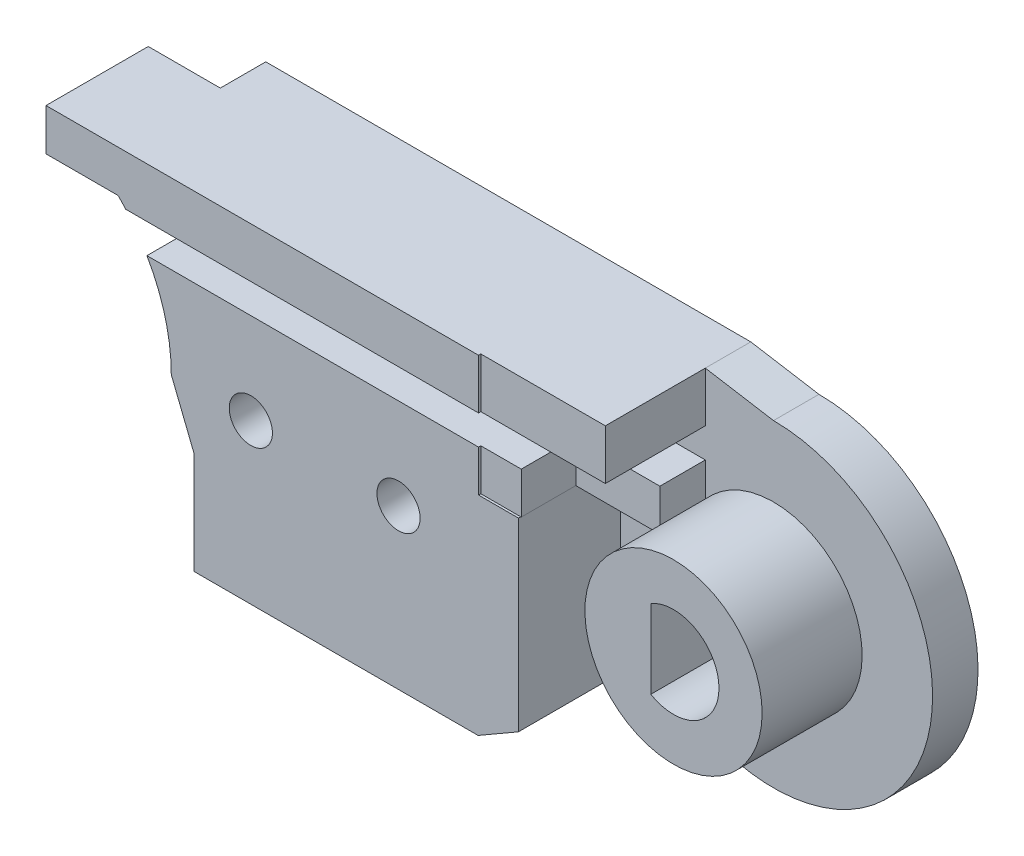
from build123d import *

# Parameters (mm, degrees)
BOSS_EXTRUDE1_DEPTH  = 2
BOSS_EXTRUDE6_DEPTH  = 4.5
CUT_EXTRUDE6_DEPTH   = 4.5
BOSS_EXTRUDE14_DEPTH = 2.3
SKETCH32_R           = 2.1
CUT_EXTRUDE7_DEPTH   = 2.3
SKETCH33_W           = 12.5
SKETCH33_H           = 1.343145751
BOSS_EXTRUDE15_DEPTH = 1.2
SKETCH35_W           = 5.479645997
SKETCH35_H           = 5.327993755
CUT_EXTRUDE8_DEPTH   = 2.4
SKETCH36_W           = 3.7
SKETCH36_H           = 1.827993755
CUT_EXTRUDE9_DEPTH   = 2.4
SKETCH37_R           = 3.9
BOSS_EXTRUDE16_DEPTH = 4.4
CUT_EXTRUDE10_DEPTH  = 7.4
SKETCH43_R           = 2.5
BOSS_EXTRUDE17_DEPTH = 1.2
SKETCH44_R           = 0.95
CUT_EXTRUDE11_DEPTH  = 11
SKETCH45_R           = 2
CUT_EXTRUDE12_DEPTH  = 4.5
SKETCH52_R           = 0.75
CUT_EXTRUDE13_DEPTH  = 10


with BuildPart() as part:
    # Sketch3 → Boss-Extrude1 (new body)
    with BuildSketch(Plane.XY):
        with BuildLine():
            Line((8, 0), (9, -2.5))
            Line((9, -2.5), (9, -7))
            Line((9, -7), (21.5, -7))
            Line((21.5, -7), (25.050252532, -4.949747468))
            ThreePointArc((25.050252532, -4.949747468), (36.467156728, -2.678784027), (30, 7))
            Line((30, 7), (27, 7.5))
            Line((27, 7.5), (5.656854249, 7.5))
            Line((5.656854249, 7.5), (5.656854249, 5.656854249))
            ThreePointArc((5.656854249, 5.656854249), (7.39103626, 3.061467459), (8, 0))
        make_face()
    extrude(amount=BOSS_EXTRUDE1_DEPTH)

    # Sketch22 → Boss-Extrude6 (add)
    with BuildSketch(Plane.XY.offset(2)):
        with BuildLine():
            Line((5.656854249, 5.656854249), (2.486790148, 5.656854249))
            Line((2.486790148, 5.656854249), (2.486790148, 7.5))
            Line((2.486790148, 7.5), (5.656854249, 7.5))
            Line((5.656854249, 7.5), (21.5, 7.5))
            Line((21.5, 7.5), (27, 7.5))
            Line((27, 7.5), (27, 2.172006245))
            Line((27, 2.172006245), (23.275126266, 2.172006245))
            Line((23.275126266, 2.172006245), (23.275126266, -5.974873734))
            Line((23.275126266, -5.974873734), (21.5, -7))
            Line((21.5, -7), (9, -7))
            Line((9, -7), (9, -2.5))
            Line((9, -2.5), (8, 0))
            ThreePointArc((8, 0), (7.39103626, 3.061467459), (5.656854249, 5.656854249))
        make_face()
    extrude(amount=BOSS_EXTRUDE6_DEPTH)

    # Sketch26 → Cut-Extrude6 (cut)
    with BuildSketch(Plane.XY.offset(2)):
        Polygon((18.098080448, 5.3), (2.530052458, 5.3), (2.530052458, 4), (18.098080448, 4), (27, 4), (27, 5.3), align=None)
    extrude(amount=CUT_EXTRUDE6_DEPTH, mode=Mode.SUBTRACT)


with BuildPart() as body_2:
    # Sketch31 → Boss-Extrude14 (new body)
    with BuildSketch(Plane.XY.offset(6.5)):
        with BuildLine():
            Line((2.432688066, 5.656854249), (0, 5.656854249))
            ThreePointArc((0, 5.656854249), (-5.656854249, 0), (0, -5.656854249))
            Line((0, -5.656854249), (9, -5.656854249))
            Line((9, -5.656854249), (9, -7))
            Line((9, -7), (21.5, -7))
            Line((21.5, -7), (23.275126266, -5.974873734))
            Line((23.275126266, -5.974873734), (23.275126266, 2.172006245))
            Line((23.275126266, 2.172006245), (27, 2.172006245))
            Line((27, 2.172006245), (27, 7.5))
            Line((27, 7.5), (2.486790148, 7.5))
            Line((2.486790148, 7.5), (2.432688066, 5.656854249))
        make_face()
    extrude(amount=BOSS_EXTRUDE14_DEPTH)

    # Sketch32 → Cut-Extrude7 (cut)
    with BuildSketch(Plane.XY.offset(8.8)):
        Circle(SKETCH32_R)
    extrude(amount=-CUT_EXTRUDE7_DEPTH, mode=Mode.SUBTRACT)

    # Sketch33 → Boss-Extrude15 (add)
    with BuildSketch(Plane.XY.offset(8.8)):
        with Locations((15.25, -6.328427125)):
            Rectangle(SKETCH33_W, SKETCH33_H)
        Polygon((2.486790148, 7.5), (21.5, 7.5), (21.5, 5.656854249), (2.432688066, 5.656854249), align=None)
    extrude(amount=BOSS_EXTRUDE15_DEPTH)


with BuildPart() as cut_extrude8_tool:
    # Sketch35 → Cut-Extrude8 (new body)
    with BuildSketch(Plane.XY.offset(8.8)):
        with Locations((24.260177002, 4.836003123)):
            Rectangle(SKETCH35_W, SKETCH35_H)
    extrude(amount=-CUT_EXTRUDE8_DEPTH)


with BuildPart() as part_1:
    add(part.part)

    # Cut-Extrude8: cut by cut_extrude8_tool
    add(cut_extrude8_tool.part, mode=Mode.SUBTRACT)

    # Sketch36 → Cut-Extrude9 (cut)
    with BuildSketch(Plane.XY.offset(6.4)):
        with Locations((25.15, 3.086003123)):
            Rectangle(SKETCH36_W, SKETCH36_H)
    extrude(amount=-CUT_EXTRUDE9_DEPTH, mode=Mode.SUBTRACT)

    # Sketch37 → Boss-Extrude16 (add)
    with BuildSketch(Plane.XY.offset(2)):
        with Locations((30, 0)):
            Circle(SKETCH37_R)
    extrude(amount=BOSS_EXTRUDE16_DEPTH)

    # Sketch39 → Cut-Extrude10 (cut, through all)
    with BuildSketch(Plane.XY.offset(6.4)):
        with BuildLine():
            Line((29, 1.732050808), (29, -1.732050808))
            ThreePointArc((29, -1.732050808), (32, 0), (29, 1.732050808))
        make_face()
    extrude(amount=-CUT_EXTRUDE10_DEPTH, mode=Mode.SUBTRACT)


with BuildPart() as body_2_1:
    add(body_2.part)

    # Cut-Extrude8: cut by cut_extrude8_tool
    add(cut_extrude8_tool.part, mode=Mode.SUBTRACT)

    # Sketch43 → Boss-Extrude17 (add)
    with BuildSketch(Plane.XY.offset(8.8)):
        with Locations((11.5, 0)):
            Circle(SKETCH43_R)
        with Locations((18, 0)):
            Circle(SKETCH43_R)
    extrude(amount=BOSS_EXTRUDE17_DEPTH)


with BuildPart() as cut_extrude11_tool:
    # Sketch44 → Cut-Extrude11 (new body, through all)
    with BuildSketch(Plane.XY.offset(10)):
        with Locations((11.5, 0)):
            Circle(SKETCH44_R)
        with Locations((18, 0)):
            Circle(SKETCH44_R)
    extrude(amount=-CUT_EXTRUDE11_DEPTH)


with BuildPart() as part_2:
    add(part_1.part)

    # Cut-Extrude11: cut by cut_extrude11_tool
    add(cut_extrude11_tool.part, mode=Mode.SUBTRACT)

    # Sketch45 → Cut-Extrude12 (cut)
    with BuildSketch(Plane(origin=(0, 0, 0), x_dir=(-1, 0, 0), z_dir=(0, 0, -1))):
        with Locations((-11.5, 0)):
            Circle(SKETCH45_R)
        with Locations((-18, 0)):
            Circle(SKETCH45_R)
    extrude(amount=-CUT_EXTRUDE12_DEPTH, mode=Mode.SUBTRACT)


with BuildPart() as body_2_2:
    add(body_2_1.part)

    # Cut-Extrude11: cut by cut_extrude11_tool
    add(cut_extrude11_tool.part, mode=Mode.SUBTRACT)

    # Sketch52 → Cut-Extrude13 (cut, along a direction that is not the sketch's normal)
    with BuildSketch(Plane.XZ.offset(-5.656854249)):
        with Locations((18.235476819, 10)):
            Circle(SKETCH52_R)
    extrude(amount=-CUT_EXTRUDE13_DEPTH, dir=(0.640410196, -0.76803306, 0), mode=Mode.SUBTRACT)


solid = part_2.part
